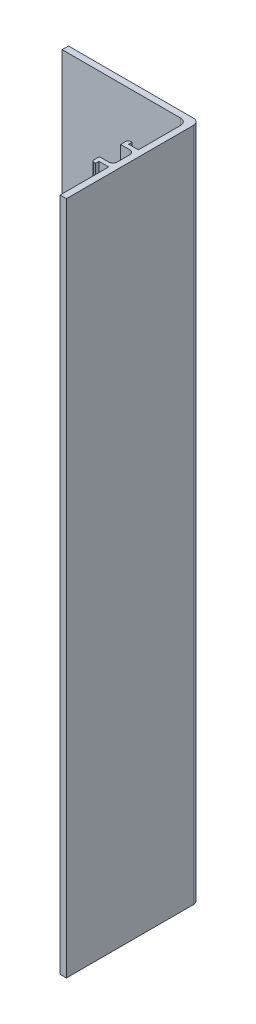
from build123d import *

# Parameters (mm, degrees)
SALIENTE_EXTRUIR1_DEPTH = 159.5
REDONDEO1_R             = 0.5
REDONDEO2_R             = 1
REDONDEO3_R             = 1.5
REDONDEO4_R             = 1.5


with BuildPart() as part:
    # Croquis1 → Saliente-Extruir1 (new body)
    with BuildSketch(Plane(origin=(0, 0, 0), x_dir=(1, 0, 0), z_dir=(0, 1, 0))):
        Polygon((0, 0), (0, 31.5), (-31, 31.5), (-31, 30), (-1.5, 30), (-1.5, 18.5), (-3.8, 18.5), (-3.8, 19.3), (-4.7, 19.3), (-4.7, 17.5), (-1.5, 17.5), (-1.5, 12.5), (-4.7, 12.5), (-4.7, 10.7), (-3.8, 10.7), (-3.8, 11.5), (-1.5, 11.5), (-1.5, 0), align=None)
    extrude(amount=SALIENTE_EXTRUIR1_DEPTH)

    # Redondeo1
    redondeo1_edges = [part.edges().sort_by_distance(p)[0] for p in [
        (-4.7, 79.75, -10.7),
        (-4.7, 79.75, -19.3),
    ]]
    fillet(redondeo1_edges, radius=REDONDEO1_R)

    # Redondeo2
    redondeo2_edges = [part.edges().sort_by_distance(p)[0] for p in [
        (-1.5, 79.75, -12.5),
        (-1.5, 79.75, -17.5),
    ]]
    fillet(redondeo2_edges, radius=REDONDEO2_R)

    # Redondeo3
    redondeo3_edges = [part.edges().sort_by_distance(p)[0] for p in [
        (-1.5, 79.75, -30),
    ]]
    fillet(redondeo3_edges, radius=REDONDEO3_R)

    # Redondeo4
    redondeo4_edges = [part.edges().sort_by_distance(p)[0] for p in [
        (0, 79.75, -31.5),
    ]]
    fillet(redondeo4_edges, radius=REDONDEO4_R)


solid = part.part
